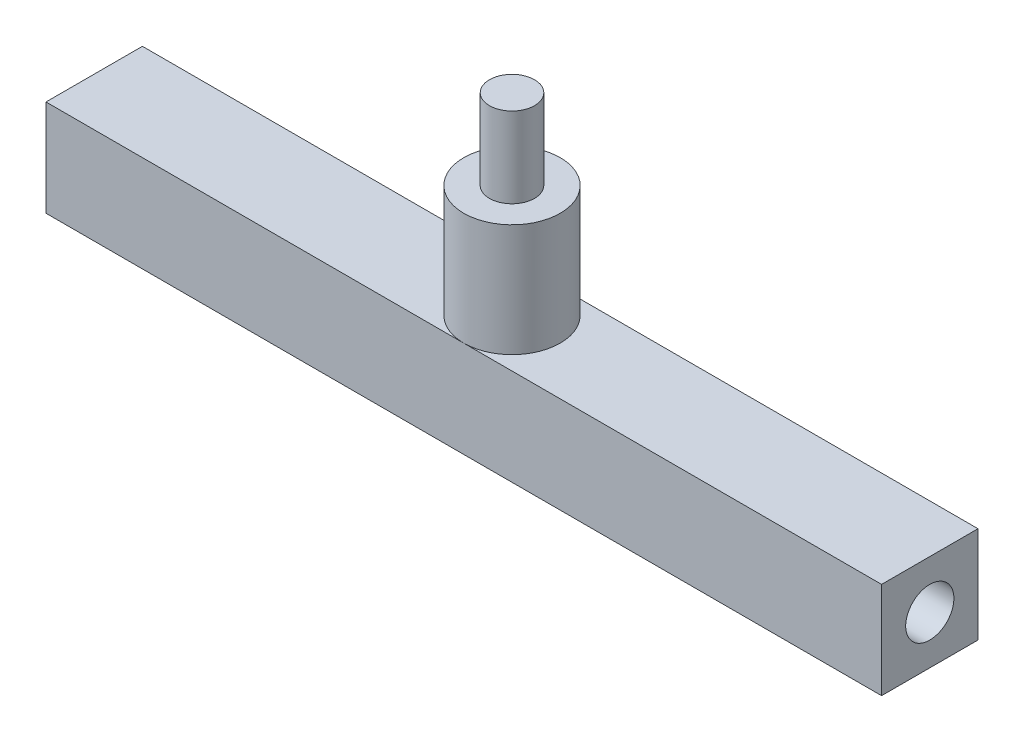
from build123d import *

# Parameters (mm, degrees)
SKETCH1_W                       = 52
SKETCH1_H                       = 6
BOSS_EXTRUDE1_DEPTH             = 6
SKETCH2_R                       = 3
BOSS_EXTRUDE2_DEPTH             = 7
SKETCH3_R                       = 1.4
BOSS_EXTRUDE3_DEPTH             = 5
M3X0_5_TAPPED_HOLE1_D           = 2.5
M3X0_5_TAPPED_HOLE1_DEPTH       = 7.5
M3X0_5_TAPPED_HOLE1_CBORE_D     = 3
M3X0_5_TAPPED_HOLE1_CBORE_DEPTH = 6
M3X0_5_TAPPED_HOLE1_TIP         = 0.751075774
M3X0_5_TAPPED_HOLE2_D           = 2.5
M3X0_5_TAPPED_HOLE2_DEPTH       = 7.5
M3X0_5_TAPPED_HOLE2_CBORE_D     = 3
M3X0_5_TAPPED_HOLE2_CBORE_DEPTH = 6
M3X0_5_TAPPED_HOLE2_TIP         = 0.751075774


with BuildPart() as part:
    # Sketch1 → Boss-Extrude1 (new body)
    with BuildSketch(Plane(origin=(0, 0, 0), x_dir=(1, 0, 0), z_dir=(0, 1, 0))):
        with Locations((26, 3)):
            Rectangle(SKETCH1_W, SKETCH1_H)
    extrude(amount=BOSS_EXTRUDE1_DEPTH)

    # Sketch2 → Boss-Extrude2 (add)
    with BuildSketch(Plane(origin=(0, 6, 0), x_dir=(1, 0, 0), z_dir=(0, 1, 0))):
        with Locations((26, 3)):
            Circle(SKETCH2_R)
    extrude(amount=BOSS_EXTRUDE2_DEPTH)

    # Sketch3 → Boss-Extrude3 (add)
    with BuildSketch(Plane(origin=(0, 13, 0), x_dir=(1, 0, 0), z_dir=(0, 1, 0))):
        with Locations((26, 3)):
            Circle(SKETCH3_R)
    extrude(amount=BOSS_EXTRUDE3_DEPTH)

    # M3x0.5 Tapped Hole1
    with Locations(Plane(origin=(52, 0, 0), x_dir=(0, 0, -1), z_dir=(1, 0, 0))):
        with Locations((3, 3)):
            CounterBoreHole(M3X0_5_TAPPED_HOLE1_D / 2, M3X0_5_TAPPED_HOLE1_CBORE_D / 2, M3X0_5_TAPPED_HOLE1_CBORE_DEPTH, depth=M3X0_5_TAPPED_HOLE1_DEPTH)
            with Locations((0, 0, -(M3X0_5_TAPPED_HOLE1_DEPTH + M3X0_5_TAPPED_HOLE1_TIP / 2))):  # 118° drill point
                Cone(0, M3X0_5_TAPPED_HOLE1_D / 2, M3X0_5_TAPPED_HOLE1_TIP, mode=Mode.SUBTRACT)

    # M3x0.5 Tapped Hole2
    with Locations(Plane.ZY):
        with Locations((-3, 3)):
            CounterBoreHole(M3X0_5_TAPPED_HOLE2_D / 2, M3X0_5_TAPPED_HOLE2_CBORE_D / 2, M3X0_5_TAPPED_HOLE2_CBORE_DEPTH, depth=M3X0_5_TAPPED_HOLE2_DEPTH)
            with Locations((0, 0, -(M3X0_5_TAPPED_HOLE2_DEPTH + M3X0_5_TAPPED_HOLE2_TIP / 2))):  # 118° drill point
                Cone(0, M3X0_5_TAPPED_HOLE2_D / 2, M3X0_5_TAPPED_HOLE2_TIP, mode=Mode.SUBTRACT)


solid = part.part
